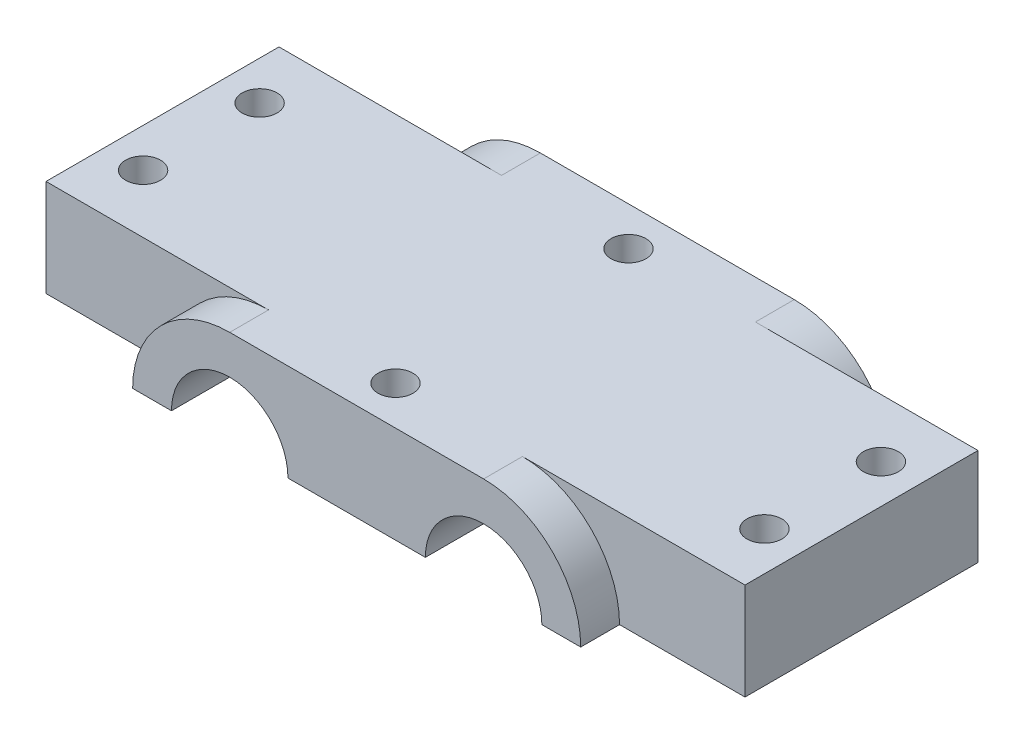
from build123d import *

# Parameters (mm, degrees)
SKETCH1_W           = 90
SKETCH1_H           = 30
BOSS_EXTRUDE1_DEPTH = 6.25
BOSS_EXTRUDE3_DEPTH = 5
CUT_EXTRUDE1_DEPTH  = 41
SKETCH6_R           = 2.25
CUT_EXTRUDE2_DEPTH  = 13.5


with BuildPart() as part:
    # Sketch1 → Boss-Extrude1 (new body, symmetric)
    with BuildSketch(Plane(origin=(0, 0, 0), x_dir=(1, 0, 0), z_dir=(0, 1, 0))):
        Rectangle(SKETCH1_W, SKETCH1_H)
    extrude(amount=BOSS_EXTRUDE1_DEPTH, both=True)

    # Sketch3 → Boss-Extrude3 (add)
    with BuildSketch(Plane.XY.offset(15)):
        with BuildLine():
            Line((-28.845871038, -6.25), (-23.845871038, -6.25))
            ThreePointArc((-23.845871038, -6.25), (-16.345871038, 1.25), (-8.845871038, -6.25))
            Line((-8.845871038, -6.25), (8.845871038, -6.25))
            ThreePointArc((8.845871038, -6.25), (16.345871038, 1.25), (23.845871038, -6.25))
            Line((23.845871038, -6.25), (28.845871038, -6.25))
            ThreePointArc((28.845871038, -6.25), (25.184705803, 2.588834765), (16.345871038, 6.25))
            Line((16.345871038, 6.25), (-16.345871038, 6.25))
            ThreePointArc((-16.345871038, 6.25), (-25.184705803, 2.588834765), (-28.845871038, -6.25))
        make_face()
    boss_extrude3 = extrude(amount=BOSS_EXTRUDE3_DEPTH)

    # Mirror1: Boss-Extrude3 across plane
    add(boss_extrude3.mirror(Plane.XY))

    # Sketch5 → Cut-Extrude1 (cut)
    with BuildSketch(Plane.XY.offset(15)):
        with BuildLine():
            Line((-23.845871038, -6.25), (-8.845871038, -6.25))
            ThreePointArc((-8.845871038, -6.25), (-16.345871038, 1.25), (-23.845871038, -6.25))
        make_face()
        with BuildLine():
            Line((8.845871038, -6.25), (23.845871038, -6.25))
            ThreePointArc((23.845871038, -6.25), (16.345871038, 1.25), (8.845871038, -6.25))
        make_face()
    extrude(amount=-CUT_EXTRUDE1_DEPTH, mode=Mode.SUBTRACT)

    # Sketch6 → Cut-Extrude2 (cut, through all)
    with BuildSketch(Plane(origin=(0, 6.25, 0), x_dir=(1, 0, 0), z_dir=(0, 1, 0))):
        with Locations(Location((-40, 7.5, 0), (0, 0, 270))):  # turned: the seam where the file's is
            Circle(SKETCH6_R)
        with Locations(Location((-40, -7.5, 0), (0, 0, 270))):  # turned: the seam where the file's is
            Circle(SKETCH6_R)
        with Locations(Location((40, -7.5, 0), (0, 0, 90))):  # turned: the seam where the file's is
            Circle(SKETCH6_R)
        with Locations(Location((40, 7.5, 0), (0, 0, 90))):  # turned: the seam where the file's is
            Circle(SKETCH6_R)
        with Locations(Location((0, 15, 0), (0, 0, 270))):  # turned: the seam where the file's is
            Circle(SKETCH6_R)
        with Locations(Location((0, -15, 0), (0, 0, 90))):  # turned: the seam where the file's is
            Circle(SKETCH6_R)
    extrude(amount=-CUT_EXTRUDE2_DEPTH, mode=Mode.SUBTRACT)


solid = part.part
